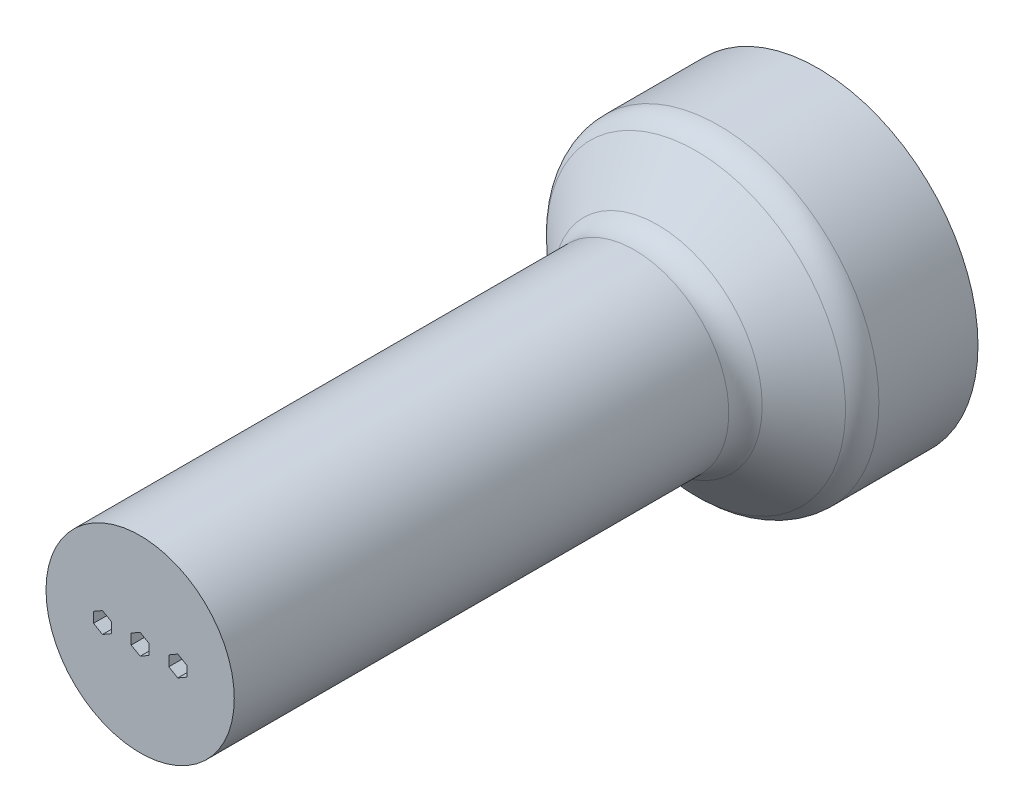
from build123d import *

# Parameters (mm, degrees)
SKETCH1_R           = 25
BOSS_EXTRUDE1_DEPTH = 150
SKETCH2_R           = 42.5
BOSS_EXTRUDE2_DEPTH = 30
FILLET4_R           = 8
FILLET5_R           = 8
SKETCH4_R           = 1.6
CUT_EXTRUDE1_DEPTH  = 30
CUT_EXTRUDE4_DEPTH  = 155
SKETCH6_R           = 10
CUT_EXTRUDE5_DEPTH  = 8


with BuildPart() as part:
    # Sketch1 → Boss-Extrude1 (new body)
    with BuildSketch(Plane.XY):
        Circle(SKETCH1_R)
    extrude(amount=BOSS_EXTRUDE1_DEPTH)

    # Sketch2 → Boss-Extrude2 (add)
    with BuildSketch(Plane.XY):
        Circle(SKETCH2_R)
    extrude(amount=-BOSS_EXTRUDE2_DEPTH)

    # Sketch3 → Revolve1 (revolve)
    with BuildSketch(Plane(origin=(0, 0, 0), x_dir=(1, 0, 0), z_dir=(0, 1, 0))):
        Polygon((25, 0), (25, -15), (42.5, 0), align=None)
    revolve(axis=Axis((0, 0, 0), (0, 0, 1)))

    # Fillet4
    fillet4_edges = [part.edges().sort_by_distance(p)[0] for p in [
        (-25, 0, 15),
    ]]
    fillet(fillet4_edges, radius=FILLET4_R)

    # Fillet5
    fillet5_edges = [part.edges().sort_by_distance(p)[0] for p in [
        (-42.5, 0, 0),
    ]]
    fillet(fillet5_edges, radius=FILLET5_R)

    # Sketch4 → Cut-Extrude1 (cut)
    with BuildSketch(Plane.XY):
        Circle(SKETCH4_R)
        with Locations((-10, 0)):
            Circle(SKETCH4_R)
        with Locations((10, 0)):
            Circle(SKETCH4_R)
    extrude(amount=-CUT_EXTRUDE1_DEPTH, mode=Mode.SUBTRACT)

    # Sketch5 → Cut-Extrude4 (cut)
    with BuildSketch(Plane.XY.offset(150)):
        Polygon((-7.61843014, -1.375), (-7.61843014, 1.375), (-10, 2.75), (-12.38156986, 1.375), (-12.38156986, -1.375), (-10, -2.75), align=None)
        Polygon((0, -2.75), (2.38156986, -1.375), (2.38156986, 1.375), (0, 2.75), (-2.38156986, 1.375), (-2.38156986, -1.375), align=None)
        Polygon((10, -2.75), (12.38156986, -1.375), (12.38156986, 1.375), (10, 2.75), (7.61843014, 1.375), (7.61843014, -1.375), align=None)
    extrude(amount=-CUT_EXTRUDE4_DEPTH, mode=Mode.SUBTRACT)

    # Sketch6 → Cut-Extrude5 (cut)
    with BuildSketch(Plane(origin=(0, 0, -30), x_dir=(-1, 0, 0), z_dir=(0, 0, -1))):
        with Locations((30, 0)):
            Circle(SKETCH6_R)
        with Locations((-30, 0)):
            Circle(SKETCH6_R)
    extrude(amount=-CUT_EXTRUDE5_DEPTH, mode=Mode.SUBTRACT)


solid = part.part
